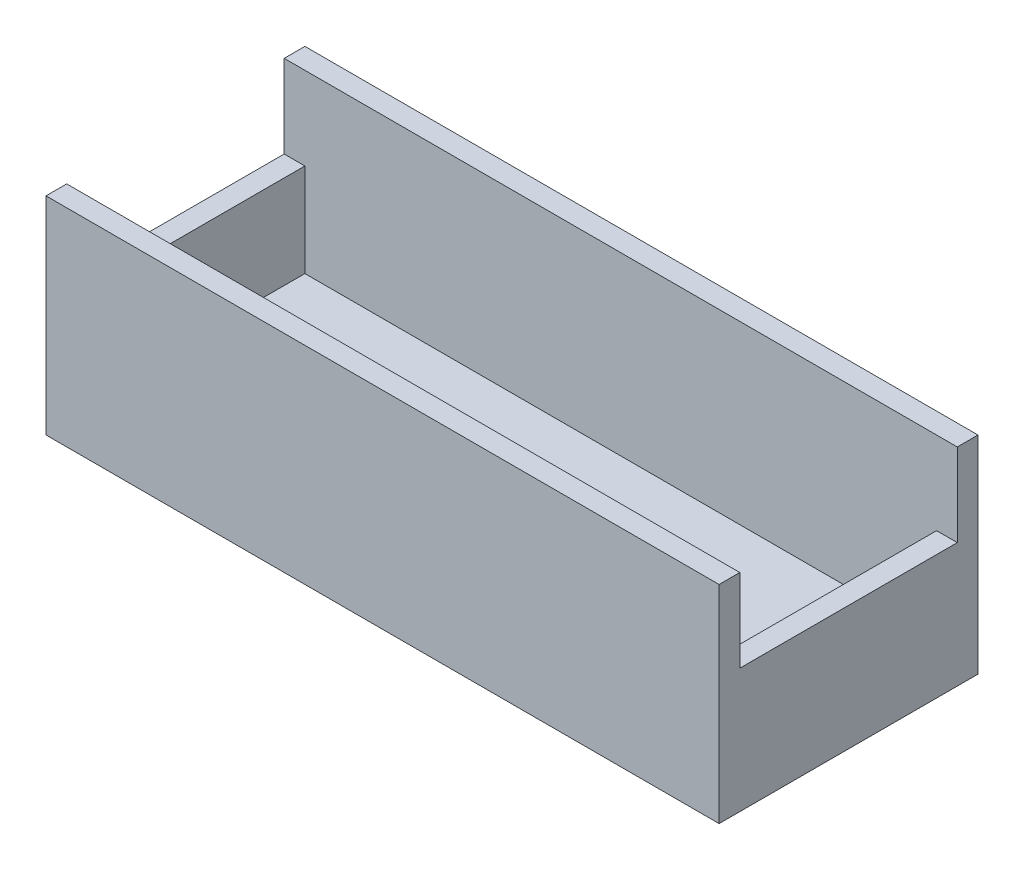
from build123d import *

# Parameters (mm, degrees)
SKETCH1_W           = 65
SKETCH1_H           = 25
BOSS_EXTRUDE1_DEPTH = 3
SKETCH2_W           = 65
SKETCH2_H           = 2
BOSS_EXTRUDE2_DEPTH = 17
SKETCH2_3_W         = 2
SKETCH2_3_H         = 21
BOSS_EXTRUDE3_DEPTH = 9


with BuildPart() as part:
    # Sketch1 → Boss-Extrude1 (new body)
    with BuildSketch(Plane(origin=(0, 0, 0), x_dir=(1, 0, 0), z_dir=(0, 1, 0))):
        with Locations((32.5, -12.5)):
            Rectangle(SKETCH1_W, SKETCH1_H)
    extrude(amount=BOSS_EXTRUDE1_DEPTH)

    # Sketch2 → Boss-Extrude2 (add)
    with BuildSketch(Plane(origin=(0, 3, 0), x_dir=(1, 0, 0), z_dir=(0, 1, 0))):
        with Locations((32.5, -1)):
            Rectangle(SKETCH2_W, SKETCH2_H)
        with Locations((32.5, -24)):
            Rectangle(SKETCH2_W, SKETCH2_H)
    extrude(amount=BOSS_EXTRUDE2_DEPTH)

    # Sketch2_3 → Boss-Extrude3 (add)
    with BuildSketch(Plane(origin=(0, 3, 0), x_dir=(1, 0, 0), z_dir=(0, 1, 0))):
        with Locations((1, -12.5)):
            Rectangle(SKETCH2_3_W, SKETCH2_3_H)
        with Locations((64, -12.5)):
            Rectangle(SKETCH2_3_W, SKETCH2_3_H)
    extrude(amount=BOSS_EXTRUDE3_DEPTH)


solid = part.part
